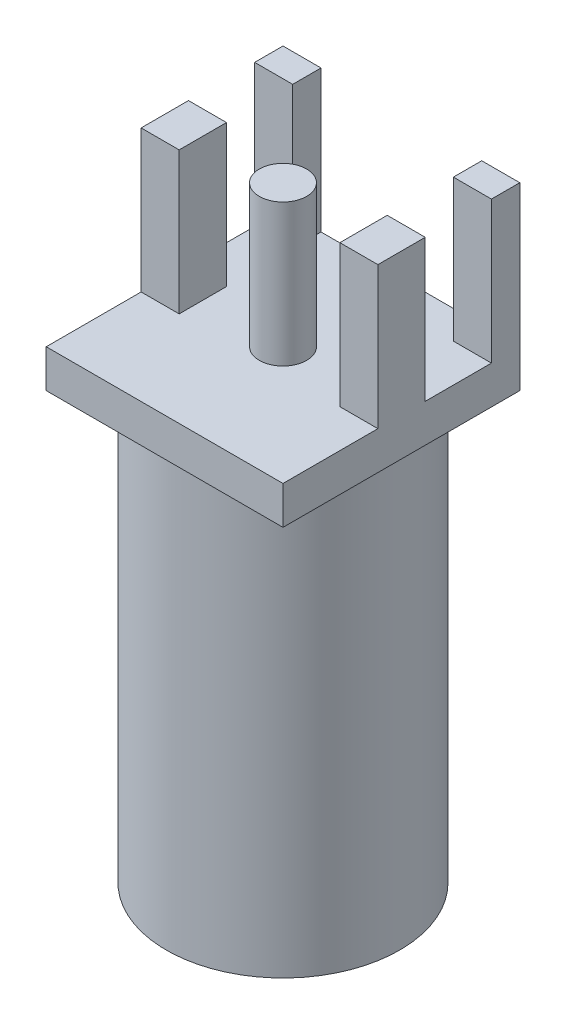
from build123d import *

# Parameters (mm, degrees)
SKETCH1_W           = 6.35
SKETCH1_H           = 6.35
BOSS_EXTRUDE1_DEPTH = 1.02
SKETCH2_W           = 1.02
SKETCH2_H           = 0.76
SKETCH2_H_2         = 1.27
BOSS_EXTRUDE2_DEPTH = 3.81
SKETCH3_R           = 0.635
BOSS_EXTRUDE3_DEPTH = 3.81
SKETCH4_R           = 3.13
BOSS_EXTRUDE4_DEPTH = 11.43


with BuildPart() as part:
    # Sketch1 → Boss-Extrude1 (new body)
    with BuildSketch(Plane(origin=(0, 0, 0), x_dir=(1, 0, 0), z_dir=(0, 1, 0))):
        Rectangle(SKETCH1_W, SKETCH1_H)
    extrude(amount=BOSS_EXTRUDE1_DEPTH)

    # Sketch2 → Boss-Extrude2 (add)
    with BuildSketch(Plane(origin=(0, 1.02, 0), x_dir=(1, 0, 0), z_dir=(0, 1, 0))):
        with Locations((-2.665, 2.795)):
            Rectangle(SKETCH2_W, SKETCH2_H)
        with Locations((-2.665, 0.005)):
            Rectangle(SKETCH2_W, SKETCH2_H_2)
        with Locations((2.665, 0.005)):
            Rectangle(SKETCH2_W, SKETCH2_H_2)
        with Locations((2.665, 2.795)):
            Rectangle(SKETCH2_W, SKETCH2_H)
    extrude(amount=BOSS_EXTRUDE2_DEPTH)

    # Sketch3 → Boss-Extrude3 (add)
    with BuildSketch(Plane(origin=(0, 1.02, 0), x_dir=(1, 0, 0), z_dir=(0, 1, 0))):
        Circle(SKETCH3_R)
    extrude(amount=BOSS_EXTRUDE3_DEPTH)

    # Sketch4 → Boss-Extrude4 (add)
    with BuildSketch(Plane.XZ):
        Circle(SKETCH4_R)
    extrude(amount=BOSS_EXTRUDE4_DEPTH)


solid = part.part
